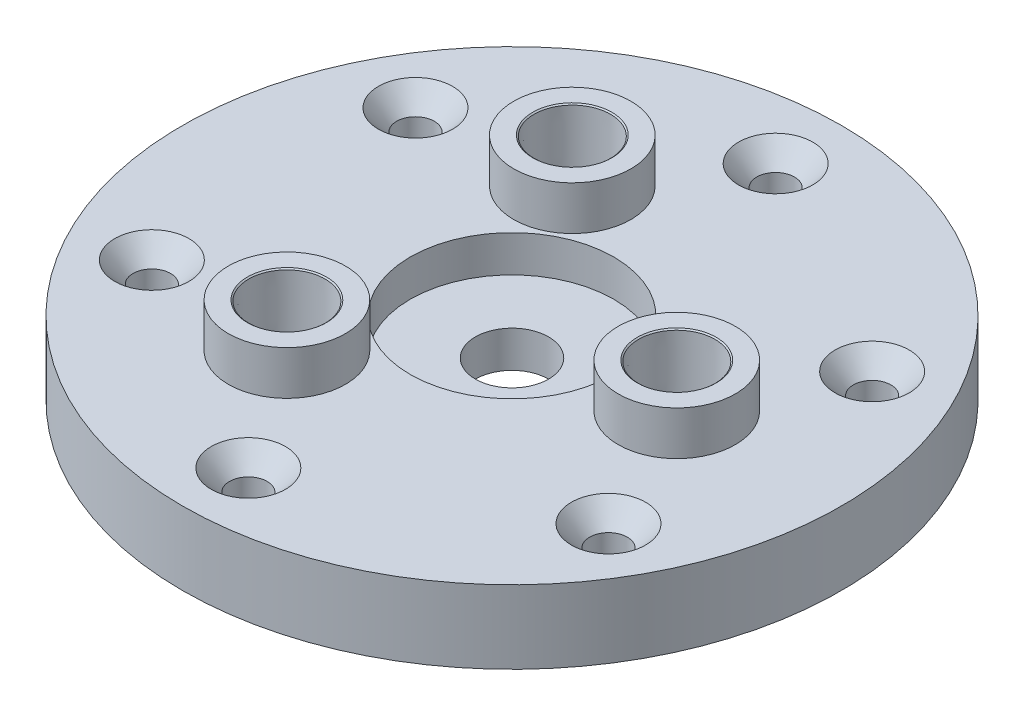
from build123d import *

# Parameters (mm, degrees)
SKETCH1_R                                        = 57.15
BOSS_EXTRUDE1_DEPTH                              = 6.35
SKETCH2_R                                        = 6.35
CUT_EXTRUDE1_DEPTH                               = 1
CUT_EXTRUDE1_DEPTH_BACK                          = 7.35
SKETCH3_R                                        = 57.15
SKETCH3_R_2                                      = 17.653
BOSS_EXTRUDE2_DEPTH                              = 6.35
ANNULUS_ENTRANCE_R                               = 3.175
CUT_EXTRUDE2_DEPTH                               = 1
CUT_EXTRUDE2_DEPTH_BACK                          = 13.7
CSK_FOR_1_4_FLAT_HEAD_MACHINE_SCREW1_D           = 6.5278
CSK_FOR_1_4_FLAT_HEAD_MACHINE_SCREW1_CSINK_D     = 12.8778
CSK_FOR_1_4_FLAT_HEAD_MACHINE_SCREW1_CSINK_ANGLE = 82
CIRPATTERN1_COUNT                                = 6
SKETCH11_R                                       = 10.16
SKETCH11_R_2                                     = 3.175
BOSS_EXTRUDE3_DEPTH                              = 7.62
F_1_4_NPT_TAPPED_HOLE3_AT_2_COUNT                = 2
F_1_4_NPT_TAPPED_HOLE3_AT_2_PITCH                = 49.493351826
F_1_4_NPT_TAPPED_HOLE3_AT_3_COUNT                = 2
F_1_4_NPT_TAPPED_HOLE3_AT_3_PITCH                = 49.493351826


with BuildPart() as part:
    # Sketch1 → Boss-Extrude1 (new body)
    with BuildSketch(Plane(origin=(0, 0, 0), x_dir=(1, 0, 0), z_dir=(0, 1, 0))):
        Circle(SKETCH1_R)
    extrude(amount=BOSS_EXTRUDE1_DEPTH)

    # Sketch2 → Cut-Extrude1 (cut, two sides)
    with BuildSketch(Plane(origin=(0, 6.35, 0), x_dir=(1, 0, 0), z_dir=(0, 1, 0))) as cut_extrude1_sk:
        Circle(SKETCH2_R)
    extrude(amount=CUT_EXTRUDE1_DEPTH, mode=Mode.SUBTRACT)
    extrude(cut_extrude1_sk.sketch, amount=-CUT_EXTRUDE1_DEPTH_BACK, mode=Mode.SUBTRACT)

    # Sketch3 → Boss-Extrude2 (add)
    with BuildSketch(Plane(origin=(0, 6.35, 0), x_dir=(1, 0, 0), z_dir=(0, 1, 0))):
        Circle(SKETCH3_R)
        Circle(SKETCH3_R_2, mode=Mode.SUBTRACT)
    extrude(amount=BOSS_EXTRUDE2_DEPTH)

    # Annulus Entrance → Cut-Extrude2 (cut, two sides)
    with BuildSketch(Plane(origin=(0, 12.7, 0), x_dir=(1, 0, 0), z_dir=(0, 1, 0))) as cut_extrude2_sk:
        with Locations((28.575, 0)):
            Circle(ANNULUS_ENTRANCE_R)
        with Locations((-14.2875, -24.746675913)):
            Circle(ANNULUS_ENTRANCE_R)
        with Locations((-14.2875, 24.746675913)):
            Circle(ANNULUS_ENTRANCE_R)
    extrude(amount=CUT_EXTRUDE2_DEPTH, mode=Mode.SUBTRACT)
    extrude(cut_extrude2_sk.sketch, amount=-CUT_EXTRUDE2_DEPTH_BACK, mode=Mode.SUBTRACT)

    # CSK for 1/4 Flat Head Machine Screw1 (through all)
    with Locations(Plane(origin=(0, 12.7, -45.72), x_dir=(0, 0, 1), z_dir=(0, 1, 0))):
        with Locations((0, 0)):
            csk_for_1_4_flat_head_machine_screw1 = CounterSinkHole(CSK_FOR_1_4_FLAT_HEAD_MACHINE_SCREW1_D / 2, CSK_FOR_1_4_FLAT_HEAD_MACHINE_SCREW1_CSINK_D / 2, counter_sink_angle=CSK_FOR_1_4_FLAT_HEAD_MACHINE_SCREW1_CSINK_ANGLE)

    # CirPattern1: CSK for 1/4 Flat Head Machine Screw1 ×6 about axis
    cirpattern1_axis = Axis((0, 0, 0), (0, 1, 0))
    for i in range(1, CIRPATTERN1_COUNT):
        add(csk_for_1_4_flat_head_machine_screw1.rotate(cirpattern1_axis, i * 360 / CIRPATTERN1_COUNT), mode=Mode.SUBTRACT)

    # Sketch11 → Boss-Extrude3 (add)
    with BuildSketch(Plane(origin=(0, 12.7, 0), x_dir=(1, 0, 0), z_dir=(0, 1, 0))):
        with Locations((-14.2875, 24.746675913)):
            Circle(SKETCH11_R)
        with Locations((-14.2875, 24.746675913)):
            Circle(SKETCH11_R_2, mode=Mode.SUBTRACT)
        with Locations((28.575, 0)):
            Circle(SKETCH11_R)
        with Locations((28.575, 0)):
            Circle(SKETCH11_R_2, mode=Mode.SUBTRACT)
        with Locations((-14.2875, -24.746675913)):
            Circle(SKETCH11_R)
        with Locations((-14.2875, -24.746675913)):
            Circle(SKETCH11_R_2, mode=Mode.SUBTRACT)
    extrude(amount=BOSS_EXTRUDE3_DEPTH)

    # Sketch13 → 1/4 NPT Tapped Hole3 (revolve, cut)
    with BuildSketch(Plane(origin=(-14.2875, 20.32, -24.746675913), x_dir=(0, 0, 1), z_dir=(1, 0, 0))):
        Polygon((0, 0), (0, 20.411147279), (5.5626, 17.0688), (5.5626, 10.0203), (6.335555425, 10.0203), (6.6298445, 0.191445196), (6.858, 0), align=None)
    f_1_4_npt_tapped_hole3 = revolve(axis=Axis((-14.2875, 26.67, -24.746675913), (0, -1, 0)), mode=Mode.SUBTRACT)

    # 1/4 NPT Tapped Hole3 at 2: 1/4 NPT Tapped Hole3 ×2
    with Locations(*[Vector(0.866025404, 0, 0.5) * (i * F_1_4_NPT_TAPPED_HOLE3_AT_2_PITCH) for i in range(1, F_1_4_NPT_TAPPED_HOLE3_AT_2_COUNT)]):
        add(f_1_4_npt_tapped_hole3, mode=Mode.SUBTRACT)

    # 1/4 NPT Tapped Hole3 at 3: 1/4 NPT Tapped Hole3 ×2
    with Locations(*[(0, 0, i * F_1_4_NPT_TAPPED_HOLE3_AT_3_PITCH) for i in range(1, F_1_4_NPT_TAPPED_HOLE3_AT_3_COUNT)]):
        add(f_1_4_npt_tapped_hole3, mode=Mode.SUBTRACT)


solid = part.part
